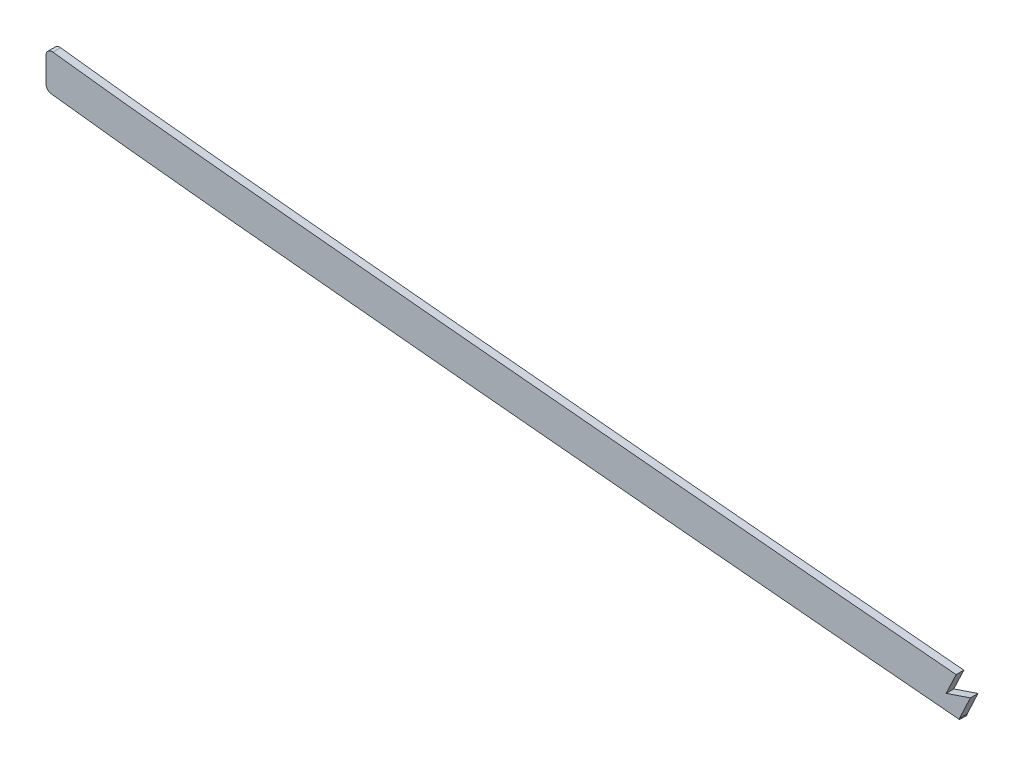
from build123d import *

# Parameters (mm, degrees)
BOSS_EXTRUDE1_DEPTH = 1.5875
FILLET1_R           = 2.54
CUT_EXTRUDE1_DEPTH  = 7.62


with BuildPart() as part:
    # Sketch2 → Boss-Extrude1 (new body, symmetric)
    with BuildSketch(Plane.XY):
        with BuildLine():
            add(Edge.make_bspline(
                [(825.5, 263.72872798), (833.004293944, 262.763036085), (840.535916247, 261.846014478), (848.126574562, 260.964164828), (892.90639318, 255.945629274), (937.686211733, 251.779150949), (973.452075064, 248.227669425), (1071.946672141, 239.051054038), (1170.441269319, 229.731506738), (1231.791940344, 224.503945813), (1324.899336146, 216.790627817), (1418.006730935, 209.040117978), (1449.742935921, 206.361809936), (1636.928606778, 190.521130342), (1824.114277635, 175.409157235), (1979.966947376, 164.299650253), (2156.268639429, 150.414433314), (2332.570330468, 133.857216402), (2354.212983157, 131.78508222), (2394.341467798, 127.847039259), (2434.469952439, 123.717187755), (2453.57670361, 121.704562273), (2472.669581058, 119.647220503), (2491.74, 117.547195763)],
                knots=[78.681340958, 78.681340958, 78.681340958, 78.681340958, 78.681340958, 78.681340958, 82.46579272, 82.46579272, 82.46579272, 100.7932901, 100.7932901, 100.7932901, 131.0989539, 131.0989539, 131.0989539, 146.7691983, 146.7691983, 146.7691983, 223.5339586, 223.5339586, 223.5339586, 233.9431167, 233.9431167, 233.9431167, 243.40815085, 243.40815085, 243.40815085, 243.40815085, 243.40815085, 243.40815085], degree=5))
            Line((825.5, 263.72872798), (825.5, 248.364439806))
            add(Edge.make_bspline(
                [(825.5, 248.364439806), (827.20768691, 248.14708351), (833.784664511, 247.321927102), (845.28106727, 245.953419483), (860.086531547, 244.295598067), (879.830703434, 242.186646028), (904.369967092, 239.698279806), (933.571022669, 236.832150625), (962.642718041, 234.023667741), (991.762593943, 231.241975908), (1021.072010315, 228.475862291), (1060.376437315, 224.796956681), (1109.513015577, 220.184378862), (1168.511190361, 214.817071985), (1227.500129793, 209.662054042), (1306.133167947, 203.021178328), (1404.361477105, 194.920725932), (1522.239851071, 184.918066624), (1640.182856491, 175.167007786), (1758.165352567, 165.757639485), (1876.155384769, 156.590937079), (1994.08749188, 147.453250142), (2092.268692061, 139.624216053), (2170.748029042, 133.079656729), (2219.771730977, 128.842227836), (2258.983988247, 125.347211495), (2288.379457536, 122.670854497), (2317.812243116, 119.931729386), (2347.551509172, 117.100365283), (2377.159899727, 114.21011853), (2406.469653851, 111.26896801), (2435.81832606, 108.240091266), (2464.242715806, 105.222889554), (2482.876892709, 103.192325927), (2491.74, 102.214848055)],
                knots=[78.875303138, 78.875303138, 78.875303138, 78.875303138, 79.386176103, 80.841530691, 82.29688528, 83.752239868, 86.662949044, 89.57365822, 92.484367397, 95.395076573, 98.305785749, 101.216494926, 107.037913278, 112.859331631, 118.680749984, 124.502168336, 136.145005042, 147.787841747, 159.430678452, 171.073515158, 182.716351863, 194.359188568, 206.002025273, 211.823443626, 217.644861979, 220.555571155, 223.466280331, 226.376989508, 229.287698684, 232.19840786, 235.109117037, 238.019826213, 240.930535389, 243.57402126, 243.57402126, 243.57402126, 243.57402126], degree=3))
            Line((2491.74, 102.214848055), (2491.74, 117.547195763))
        make_face()
    extrude(amount=BOSS_EXTRUDE1_DEPTH, both=True)

    # Fillet1
    fillet1_edges = [part.edges().sort_by_distance(p)[0] for p in [
        (2491.74, 102.214848055, -0.79375),
        (2491.74, 117.547195763, -0.79375),
        (825.5, 248.364439806, -0.79375),
        (825.5, 263.72872798, 0.79375),
    ]]
    fillet(fillet1_edges, radius=FILLET1_R)

    # Sketch3 → Cut-Extrude1 (cut)
    with BuildSketch(Plane.XY.offset(1.5875)):
        Polygon((1201.641901464, 227.227804562), (1201.641901464, 233.657871268), (2527.666884392, 125.867495718), (2495.375554416, 68.882795761), (1203.044971141, 209.52849605), (1203.044971141, 212.261982037), (1207.495802024, 221.814984909), (1197.508571749, 218.449722533), align=None)
    extrude(amount=-CUT_EXTRUDE1_DEPTH, mode=Mode.SUBTRACT)


solid = part.part
